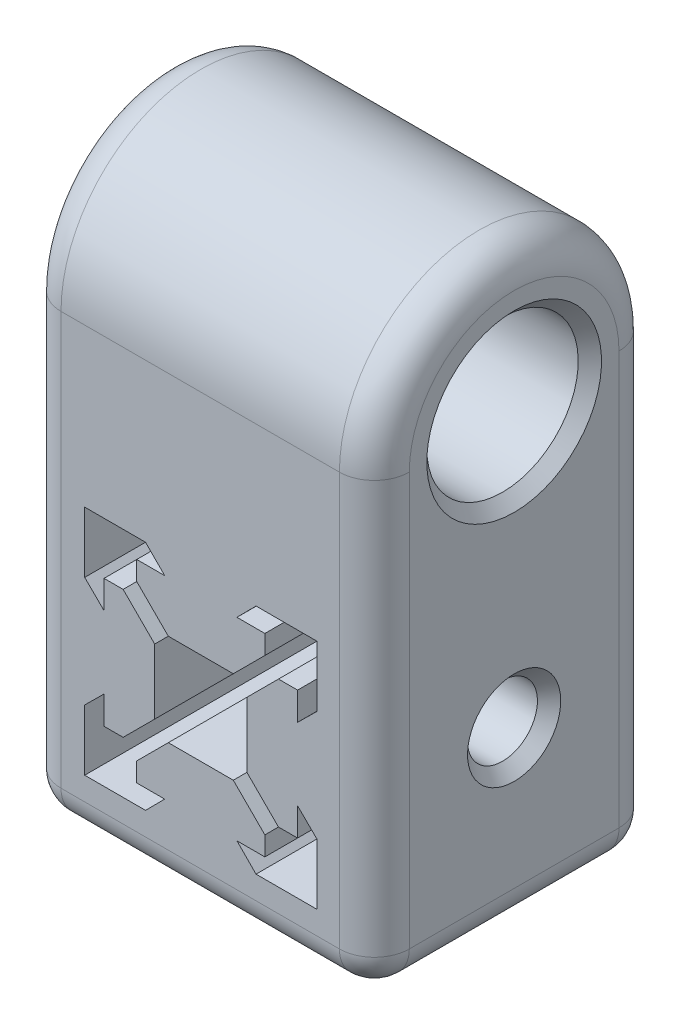
from build123d import *

# Parameters (mm, degrees)
BOSS_EXTRUDE1_DEPTH = 24
SKETCH5_R           = 6.5
BOSS_EXTRUDE3_DEPTH = 29.899298
SKETCH3_R           = 3
CUT_EXTRUDE1_DEPTH  = 30.899298428
FILLET1_R           = 3
CHAMFER1_SIZE       = 1


with BuildPart() as part:
    # Sketch1 → Boss-Extrude1 (new body)
    with BuildSketch(Plane.XY):
        Polygon((0, 15), (14.899298428, 15), (14.899298428, -14.949649214), (-15, -14.949649214), (-15, 15), align=None)
        Polygon((-9.966432809, 9.966432809), (-4.741432809, 9.966432809), (-3.1, 8.307461143), (-5.5, 8.307461143), (-5.5, 6.667461143), (-2.79, 3.957461143), (2.79, 3.957461143), (5.5, 6.667461143), (5.5, 8.307461143), (3.1, 8.307461143), (4.741432809, 9.966432809), (9.966432809, 9.966432809), (9.966432809, 4.741432809), (8.307461143, 3.1), (8.307461143, 5.5), (6.667461143, 5.5), (3.957461143, 2.79), (3.957461143, -2.79), (6.667461143, -5.5), (8.307461143, -5.5), (8.307461143, -3.1), (9.966432809, -4.741432809), (9.966432809, -9.966432809), (4.741432809, -9.966432809), (3.1, -8.307461143), (5.5, -8.307461143), (5.5, -6.667461143), (2.79, -3.957461143), (-2.79, -3.957461143), (-5.5, -6.667461143), (-5.5, -8.307461143), (-3.1, -8.307461143), (-4.741432809, -9.966432809), (-9.966432809, -9.966432809), (-9.966432809, -4.741432809), (-8.307461143, -3.1), (-8.307461143, -5.5), (-6.667461143, -5.5), (-3.957461143, -2.79), (-3.957461143, 2.79), (-6.667461143, 5.5), (-8.307461143, 5.5), (-8.307461143, 3.1), (-9.966432809, 4.741432809), align=None, mode=Mode.SUBTRACT)
    extrude(amount=BOSS_EXTRUDE1_DEPTH)

    # Sketch5 → Boss-Extrude3 (add, through all)
    with BuildSketch(Plane.ZY.offset(15)):
        with BuildLine():
            Line((0, 15), (24, 15))
            Line((24, 15), (24, 23.5))
            ThreePointArc((24, 23.5), (12, 35.5), (0, 23.5))
            Line((0, 23.5), (0, 15))
        make_face()
        with Locations((12, 23.5)):
            Circle(SKETCH5_R, mode=Mode.SUBTRACT)
    extrude(amount=-BOSS_EXTRUDE3_DEPTH)

    # Sketch3 → Cut-Extrude1 (cut, through all)
    with BuildSketch(Plane.ZY.offset(15)):
        with Locations((12, 0)):
            Circle(SKETCH3_R)
    extrude(amount=-CUT_EXTRUDE1_DEPTH, mode=Mode.SUBTRACT)

    # Fillet1
    fillet1_edges = [part.edges().sort_by_distance(p)[0] for p in [
        (-0.050350786, -14.949649214, 24),
        (14.899298428, 0.025175393, 24),
        (14.899298, 35.5, 12),
        (-15, 35.5, 12),
        (14.899298428, 0.025175393, 0),
        (-0.050350786, -14.949649214, 0),
        (-15, 4.275175393, 0),
        (-15, 4.275175393, 24),
        (14.899298428, -14.949649214, 12),
        (-15, -14.949649214, 12),
    ]]
    fillet(fillet1_edges, radius=FILLET1_R)

    # Chamfer1
    chamfer1_edges = [part.edges().sort_by_distance(p)[0] for p in [
        (14.899298, 23.5, 5.5),
        (-15, 23.5, 5.5),
        (14.899298428, 0, 9),
        (-15, 0, 9),
    ]]
    chamfer(chamfer1_edges, length=CHAMFER1_SIZE)


solid = part.part
